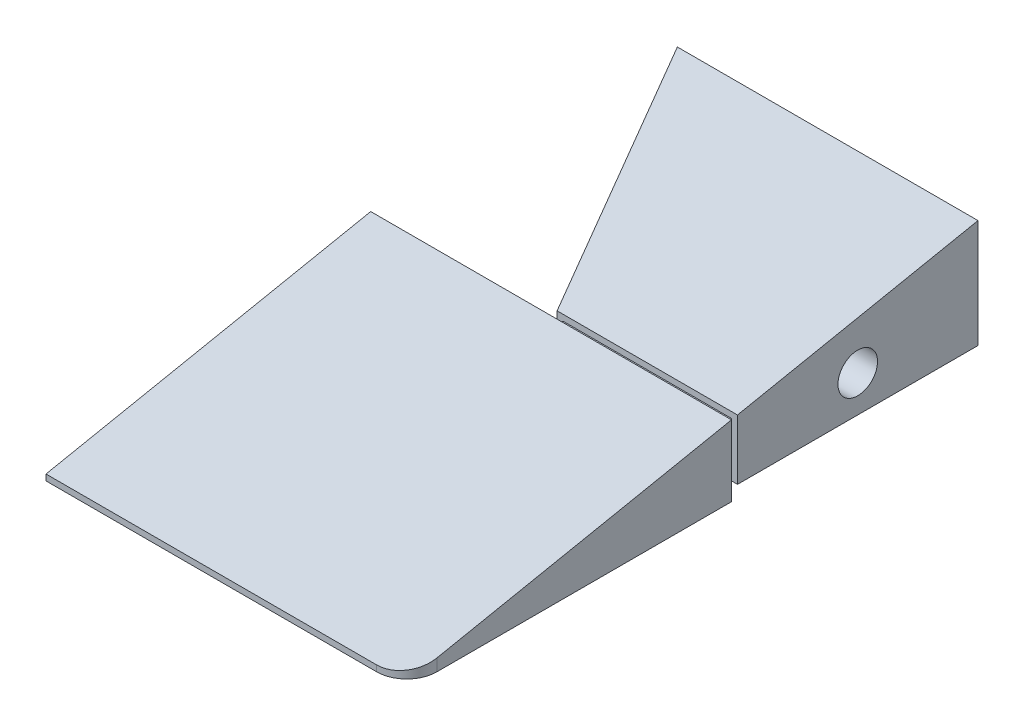
from build123d import *

# Parameters (mm, degrees)
ESBO_O1_W                                      = 130
ESBO_O1_H                                      = 20
RESSALTO_EXTRUS_O1_DEPTH                       = 95
CORTE_EXTRUS_O2_REACH                          = 22
CORTE_EXTRUS_O3_DEPTH                          = 1
CORTE_EXTRUS_O3_DEPTH_BACK                     = 61
BROCA_DE_ROSQUEAR_DE_CANO_PARA_TARRAXA_D_D     = 6.579997
BROCA_DE_ROSQUEAR_DE_CANO_PARA_TARRAXA_D_DEPTH = 10
BROCA_DE_ROSQUEAR_DE_CANO_PARA_TARRAXA_D_TIP   = 1.976830535
BROCA_DE_ROSQUEAR_DE_CANO_PARA_TARRA_2_D       = 6.579997
BROCA_DE_ROSQUEAR_DE_CANO_PARA_TARRA_2_DEPTH   = 10
BROCA_DE_ROSQUEAR_DE_CANO_PARA_TARRA_2_TIP     = 1.976830535
FILETE2_R                                      = 5
CORTE_EXTRUS_O4_REACH                          = 62
RESSALTO_EXTRUS_O2_REACH                       = 57
ESBO_O13_W                                     = 28
ESBO_O13_H                                     = 8
ESBO_O14_W                                     = 50
ESBO_O14_H                                     = 2
CORTE_EXTRUS_O5_DEPTH                          = 40.5


with BuildPart() as part:
    # Esboço1 → Ressalto-extrusão1 (new body)
    with BuildSketch(Plane.XY):
        Rectangle(ESBO_O1_W, ESBO_O1_H)
    extrude(amount=RESSALTO_EXTRUS_O1_DEPTH)

    # Esboço2 → Corte-extrusão2 (cut, up to next)
    with BuildSketch(Plane(origin=(0, 10, 0), x_dir=(1, 0, 0), z_dir=(0, 1, 0)), mode=Mode.PRIVATE) as corte_extrus_o2_sk1:
        Polygon((15, 0), (-65, 0), (-65, -95), (5, -95), (5, -41), (35, -41), (35, -40), align=None)
    corte_extrus_o2_tool1 = extrude(corte_extrus_o2_sk1.sketch, amount=-CORTE_EXTRUS_O2_REACH, mode=Mode.PRIVATE) & part.part
    add(corte_extrus_o2_tool1.solids().sort_by_distance((-24.897504, 10, 44.887255))[0], mode=Mode.SUBTRACT)

    # Esboço3 → Corte-extrusão3 (cut, two sides)
    with BuildSketch(Plane(origin=(65, 0, 0), x_dir=(0, 0, -1), z_dir=(1, 0, 0))) as corte_extrus_o3_sk:
        Polygon((200.200134404, 50.040026881), (0, 10), (-95, -9), (-295.200134404, -49.040026881), (-375.280188165, 351.360241926), (120.120080642, 450.440295688), align=None)
    extrude(amount=CORTE_EXTRUS_O3_DEPTH, mode=Mode.SUBTRACT)
    extrude(corte_extrus_o3_sk.sketch, amount=-CORTE_EXTRUS_O3_DEPTH_BACK, mode=Mode.SUBTRACT)

    # Broca de rosquear de cano para tarraxa d
    with Locations(Plane(origin=(65, 0, 0), x_dir=(0, 0, -1), z_dir=(1, 0, 0))):
        with Locations((-20, -1.945)):
            Hole(BROCA_DE_ROSQUEAR_DE_CANO_PARA_TARRAXA_D_D / 2, depth=BROCA_DE_ROSQUEAR_DE_CANO_PARA_TARRAXA_D_DEPTH)
            with Locations((0, 0, -(BROCA_DE_ROSQUEAR_DE_CANO_PARA_TARRAXA_D_DEPTH + BROCA_DE_ROSQUEAR_DE_CANO_PARA_TARRAXA_D_TIP / 2))):  # 118° drill point
                Cone(0, BROCA_DE_ROSQUEAR_DE_CANO_PARA_TARRAXA_D_D / 2, BROCA_DE_ROSQUEAR_DE_CANO_PARA_TARRAXA_D_TIP, mode=Mode.SUBTRACT)

    # Broca de rosquear de cano para tarra 2
    with Locations(Plane(origin=(12, 0, -6), x_dir=(0.447213595, 0, 0.894427191), z_dir=(-0.894427191, 0, 0.447213595))):
        with Locations((26.708203932, -1.945)):
            Hole(BROCA_DE_ROSQUEAR_DE_CANO_PARA_TARRA_2_D / 2, depth=BROCA_DE_ROSQUEAR_DE_CANO_PARA_TARRA_2_DEPTH)
            with Locations((0, 0, -(BROCA_DE_ROSQUEAR_DE_CANO_PARA_TARRA_2_DEPTH + BROCA_DE_ROSQUEAR_DE_CANO_PARA_TARRA_2_TIP / 2))):  # 118° drill point
                Cone(0, BROCA_DE_ROSQUEAR_DE_CANO_PARA_TARRA_2_D / 2, BROCA_DE_ROSQUEAR_DE_CANO_PARA_TARRA_2_TIP, mode=Mode.SUBTRACT)

    # Filete2
    filete2_edges = [part.edges().sort_by_distance(p)[0] for p in [
        (65, -9.5, 95),
    ]]
    fillet(filete2_edges, radius=FILETE2_R)

    # Esboço12 → Corte-extrusão4 (cut, up to next)
    with BuildSketch(Plane(origin=(65, 0, 0), x_dir=(0, 0, -1), z_dir=(1, 0, 0)), mode=Mode.PRIVATE) as corte_extrus_o4_sk1:
        Polygon((-41, -10), (-41, 1.8), (-40, 2), (-40, -10), align=None)
    corte_extrus_o4_tool1 = extrude(corte_extrus_o4_sk1.sketch, amount=-CORTE_EXTRUS_O4_REACH, mode=Mode.PRIVATE) & part.part
    add(corte_extrus_o4_tool1.solids().sort_by_distance((65, -4.04986, 40.498599))[0], mode=Mode.SUBTRACT)

    # Esboço13 → Ressalto-extrusão2 (add, up to next)
    with BuildSketch(Plane.XY.offset(40), mode=Mode.PRIVATE) as ressalto_extrus_o2_sk1:
        with Locations((50, -3)):
            Rectangle(ESBO_O13_W, ESBO_O13_H)
    ressalto_extrus_o2_tool1 = extrude(ressalto_extrus_o2_sk1.sketch, amount=RESSALTO_EXTRUS_O2_REACH, mode=Mode.PRIVATE) - part.part
    add(ressalto_extrus_o2_tool1.solids().sort_by_distance((50, -3, 40))[0])

    # Esboço14 → Corte-extrusão5 (cut)
    with BuildSketch(Plane(origin=(0, 0, 0), x_dir=(-1, 0, 0), z_dir=(0, 0, -1))):
        with Locations((-40, -9)):
            Rectangle(ESBO_O14_W, ESBO_O14_H)
    extrude(amount=-CORTE_EXTRUS_O5_DEPTH, mode=Mode.SUBTRACT)


solid = part.part
